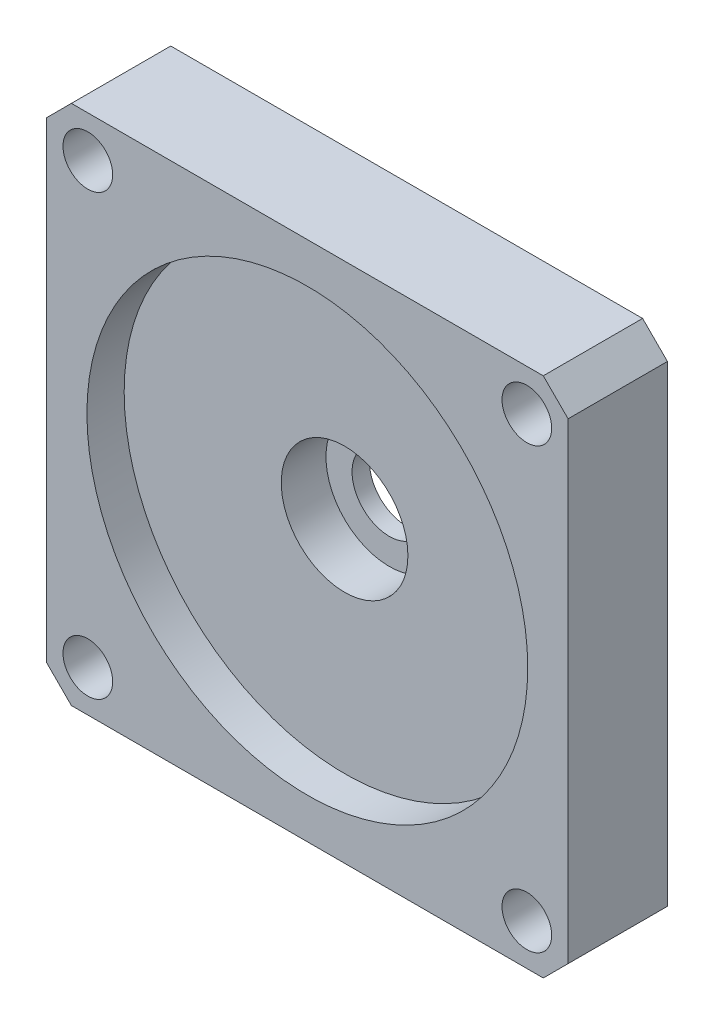
from build123d import *

# Parameters (mm, degrees)
SKETCH_1_W          = 42
SKETCH_1_H          = 42
EXTRUDE_1_DEPTH     = 8
CUT_EXTRUDE_1_REACH = 10
SKETCH_2_R          = 2
SKETCH_3_R          = 17.75
CUT_EXTRUDE_2_DEPTH = 3
SKETCH_4_R          = 5.1
CUT_EXTRUDE_3_DEPTH = 3.6
CUT_EXTRUDE_4_REACH = 3.4
SKETCH_5_R          = 3
CHAMFER_1_SIZE      = 2


with BuildPart() as part:
    # 草图1 → 凸台-拉伸1 (new body)
    with BuildSketch(Plane.XY):
        Rectangle(SKETCH_1_W, SKETCH_1_H)
    extrude(amount=EXTRUDE_1_DEPTH)

    # 草图2 → 切除-拉伸1 (cut, up to next)
    with BuildSketch(Plane.XY.offset(8), mode=Mode.PRIVATE) as cut_extrude_1_sk1:
        with Locations((-17.67766953, 17.67766953)):
            Circle(SKETCH_2_R)
    cut_extrude_1_tool1 = extrude(cut_extrude_1_sk1.sketch, amount=-CUT_EXTRUDE_1_REACH, mode=Mode.PRIVATE) & part.part
    add(cut_extrude_1_tool1.solids().sort_by_distance((-17.67767, 17.67767, 8))[0], mode=Mode.SUBTRACT)
    # 草图2 → 切除-拉伸1 (cut, up to next)
    with BuildSketch(Plane.XY.offset(8), mode=Mode.PRIVATE) as cut_extrude_1_sk2:
        with Locations((17.67766953, 17.67766953)):
            Circle(SKETCH_2_R)
    cut_extrude_1_tool2 = extrude(cut_extrude_1_sk2.sketch, amount=-CUT_EXTRUDE_1_REACH, mode=Mode.PRIVATE) & part.part
    add(cut_extrude_1_tool2.solids().sort_by_distance((17.67767, 17.67767, 8))[0], mode=Mode.SUBTRACT)
    # 草图2 → 切除-拉伸1 (cut, up to next)
    with BuildSketch(Plane.XY.offset(8), mode=Mode.PRIVATE) as cut_extrude_1_sk3:
        with Locations((17.67766953, -17.67766953)):
            Circle(SKETCH_2_R)
    cut_extrude_1_tool3 = extrude(cut_extrude_1_sk3.sketch, amount=-CUT_EXTRUDE_1_REACH, mode=Mode.PRIVATE) & part.part
    add(cut_extrude_1_tool3.solids().sort_by_distance((17.67767, -17.67767, 8))[0], mode=Mode.SUBTRACT)
    # 草图2 → 切除-拉伸1 (cut, up to next)
    with BuildSketch(Plane.XY.offset(8), mode=Mode.PRIVATE) as cut_extrude_1_sk4:
        with Locations((-17.67766953, -17.67766953)):
            Circle(SKETCH_2_R)
    cut_extrude_1_tool4 = extrude(cut_extrude_1_sk4.sketch, amount=-CUT_EXTRUDE_1_REACH, mode=Mode.PRIVATE) & part.part
    add(cut_extrude_1_tool4.solids().sort_by_distance((-17.67767, -17.67767, 8))[0], mode=Mode.SUBTRACT)

    # 草图3 → 切除-拉伸2 (cut)
    with BuildSketch(Plane.XY.offset(8)):
        Circle(SKETCH_3_R)
    extrude(amount=-CUT_EXTRUDE_2_DEPTH, mode=Mode.SUBTRACT)

    # 草图4 → 切除-拉伸3 (cut)
    with BuildSketch(Plane.XY.offset(5)):
        Circle(SKETCH_4_R)
    extrude(amount=-CUT_EXTRUDE_3_DEPTH, mode=Mode.SUBTRACT)

    # 草图5 → 切除-拉伸4 (cut, up to next)
    with BuildSketch(Plane.XY.offset(1.4), mode=Mode.PRIVATE) as cut_extrude_4_sk1:
        Circle(SKETCH_5_R)
    cut_extrude_4_tool1 = extrude(cut_extrude_4_sk1.sketch, amount=-CUT_EXTRUDE_4_REACH, mode=Mode.PRIVATE) & part.part
    add(cut_extrude_4_tool1.solids().sort_by_distance((0, 0, 1.4))[0], mode=Mode.SUBTRACT)

    # 倒角1
    chamfer_1_edges = [part.edges().sort_by_distance(p)[0] for p in [
        (21, -21, 4),
        (-21, -21, 4),
        (-21, 21, 4),
        (21, 21, 4),
    ]]
    chamfer(chamfer_1_edges, length=CHAMFER_1_SIZE)


solid = part.part
